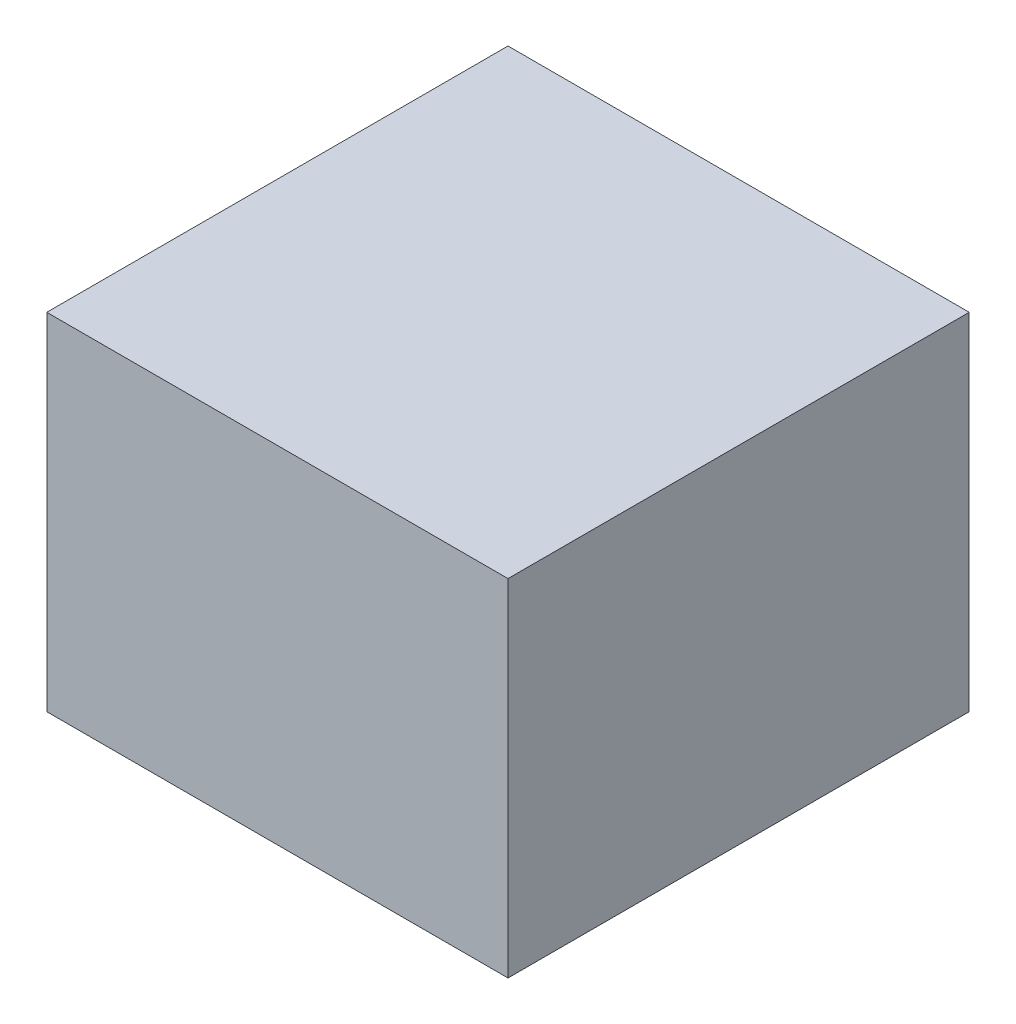
from build123d import *

# Parameters (mm, degrees)
SKETCH1_W           = 25.4
SKETCH1_H           = 25.4
BOSS_EXTRUDE1_DEPTH = 19.05


with BuildPart() as part:
    # Sketch1 → Boss-Extrude1 (new body)
    with BuildSketch(Plane(origin=(0, 0, 0), x_dir=(1, 0, 0), z_dir=(0, 1, 0))):
        Rectangle(SKETCH1_W, SKETCH1_H)
    extrude(amount=BOSS_EXTRUDE1_DEPTH)


solid = part.part
